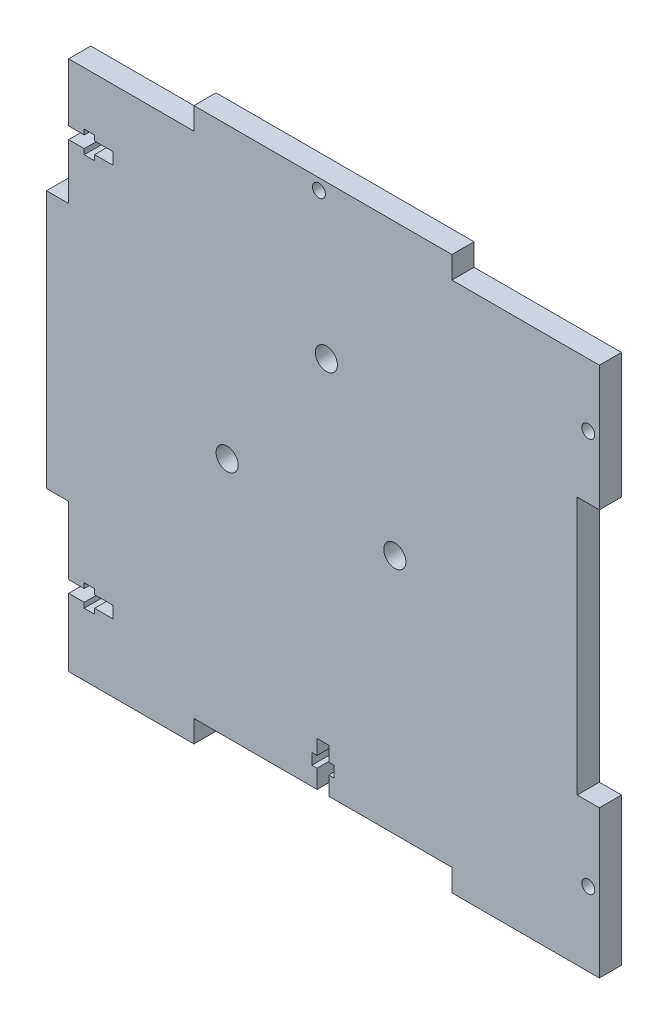
from build123d import *

# Parameters (mm, degrees)
SKETCH1_R           = 1.75
BOSS_EXTRUDE2_DEPTH = 6
SKETCH2_R           = 3
CUT_EXTRUDE1_DEPTH  = 7


with BuildPart() as part:
    # Sketch1 → Boss-Extrude2 (new body)
    with BuildSketch(Plane.XY):
        Polygon((72, 72), (32, 72), (32, 78), (-38, 78), (-38, 72), (-72, 72), (-72, 56.2), (-67.772810154, 56.2), (-67.772810154, 57.6), (-64.957983727, 57.6), (-64.957983727, 56.2), (-60, 56.2), (-60, 53), (-64.957983727, 53), (-64.957983727, 51.568504207), (-67.772810154, 51.568504207), (-67.772810154, 53), (-72, 53), (-72, 38), (-78, 38), (-78, -32), (-72, -32), (-72, -50.4), (-67.78187279, -50.4), (-67.78187279, -49), (-64.967046362, -49), (-64.967046362, -50.4), (-60, -50.4), (-60, -53.6), (-64.967046362, -53.6), (-64.967046362, -55), (-67.78187279, -55), (-67.78187279, -53.6), (-72, -53.6), (-72, -72), (-38, -72), (-38, -66), (-4.6, -66), (-4.6, -61), (-6, -61), (-6, -58), (-4.6, -58), (-4.6, -54), (-1.4, -54), (-1.4, -58), (0, -58), (0, -61), (-1.4, -61), (-1.4, -66), (32, -66), (32, -72), (72, -72), (72, -32), (66, -32), (66, 38), (72, 38), align=None)
        with Locations((69, -52)):
            Circle(SKETCH1_R, mode=Mode.SUBTRACT)
        with Locations((69, 55)):
            Circle(SKETCH1_R, mode=Mode.SUBTRACT)
        with Locations((-4.09, 75)):
            Circle(SKETCH1_R, mode=Mode.SUBTRACT)
    extrude(amount=BOSS_EXTRUDE2_DEPTH)

    # Sketch2 → Cut-Extrude1 (cut, through all)
    with BuildSketch(Plane(origin=(0, 0, 0), x_dir=(-1, 0, 0), z_dir=(0, 0, -1))):
        with Locations((2.075257159, 36.491728523)):
            Circle(SKETCH2_R)
        with Locations((-16.5, -0.5)):
            Circle(SKETCH2_R)
        with Locations((29, -0.5)):
            Circle(SKETCH2_R)
    extrude(amount=-CUT_EXTRUDE1_DEPTH, mode=Mode.SUBTRACT)


solid = part.part
